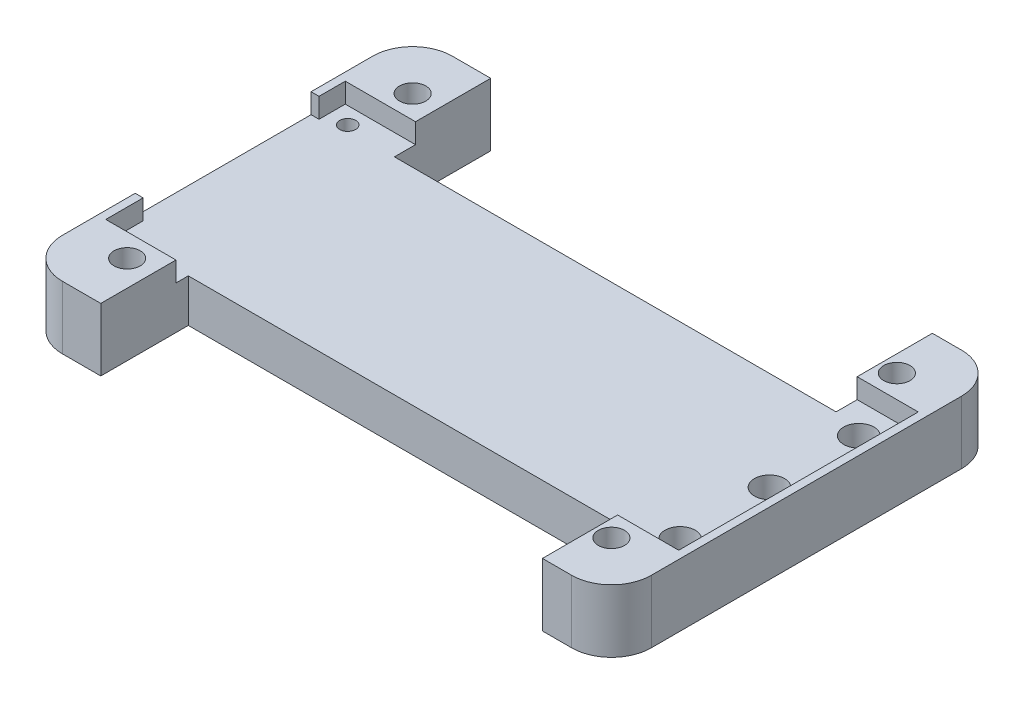
from build123d import *

# Parameters (mm, degrees)
SKETCH1_W           = 74
SKETCH1_H           = 49
BOSS_EXTRUDE1_DEPTH = 7.9
FILLET1_R           = 5
SKETCH3_R           = 1.65
CUT_EXTRUDE6_DEPTH  = 7.9
SKETCH9_R           = 1.9
SKETCH9_R_2         = 1
CUT_EXTRUDE7_DEPTH  = 7.9
CUT_EXTRUDE8_DEPTH  = 2.5
SKETCH11_W          = 55.5
SKETCH11_H          = 12.1
CUT_EXTRUDE9_DEPTH  = 7.9
CUT_EXTRUDE10_DEPTH = 7.9
SKETCH15_W          = 55.5
SKETCH15_H          = 3
CUT_EXTRUDE11_DEPTH = 10


with BuildPart() as part:
    # Sketch1 → Boss-Extrude1 (new body)
    with BuildSketch(Plane(origin=(0, 0, 0), x_dir=(1, 0, 0), z_dir=(0, 1, 0))):
        Rectangle(SKETCH1_W, SKETCH1_H)
    extrude(amount=BOSS_EXTRUDE1_DEPTH)

    # Fillet1
    fillet1_edges = [part.edges().sort_by_distance(p)[0] for p in [
        (37, 3.95, 24.5),
        (-37, 3.95, 24.5),
        (-37, 3.95, -24.5),
        (37, 3.95, -24.5),
    ]]
    fillet(fillet1_edges, radius=FILLET1_R)

    # Sketch3 → Cut-Extrude6 (cut)
    with BuildSketch(Plane(origin=(0, 7.9, 0), x_dir=(1, 0, 0), z_dir=(0, 1, 0))):
        with Locations((-30.424, 17.9375)):
            Circle(SKETCH3_R)
        with Locations((30.424, 17.9375)):
            Circle(SKETCH3_R)
        with Locations((-30.424, -17.9375)):
            Circle(SKETCH3_R)
        with Locations((30.424, -17.9375)):
            Circle(SKETCH3_R)
    extrude(amount=-CUT_EXTRUDE6_DEPTH, mode=Mode.SUBTRACT)

    # Sketch9 → Cut-Extrude7 (cut)
    with BuildSketch(Plane(origin=(0, 7.9, 0), x_dir=(1, 0, 0), z_dir=(0, 1, 0))):
        with Locations((32.354, 11.2275)):
            Circle(SKETCH9_R)
        with Locations((32.354, 0.0025)):
            Circle(SKETCH9_R)
        with Locations((32.354, -11.2275)):
            Circle(SKETCH9_R)
        with Locations((-33.584, 12.9375)):
            Circle(SKETCH9_R_2)
    extrude(amount=-CUT_EXTRUDE7_DEPTH, mode=Mode.SUBTRACT)

    # Sketch10 → Cut-Extrude8 (cut)
    with BuildSketch(Plane(origin=(0, 7.9, 0), x_dir=(1, 0, 0), z_dir=(0, 1, 0))):
        Polygon((36, 15.05), (36, -15.05), (-36, -15.05), (-36, -10.35), (-37, -10.35), (-37, 11.75), (-36, 11.75), (-36, 15.05), align=None)
    extrude(amount=-CUT_EXTRUDE8_DEPTH, mode=Mode.SUBTRACT)

    # Sketch11 → Cut-Extrude9 (cut)
    with BuildSketch(Plane(origin=(0, 7.9, 0), x_dir=(1, 0, 0), z_dir=(0, 1, 0))):
        with Locations((0.574, 18.45)):
            Rectangle(SKETCH11_W, SKETCH11_H)
    extrude(amount=-CUT_EXTRUDE9_DEPTH, mode=Mode.SUBTRACT)

    # Sketch12 → Cut-Extrude10 (cut)
    with BuildSketch(Plane(origin=(0, 7.9, 0), x_dir=(1, 0, 0), z_dir=(0, 1, 0))):
        Polygon((-27.176, -15.05), (-27.176, -13.5), (28.324, -13.5), (28.324, -15.05), (28.324, -21.5), (-27.176, -21.5), align=None)
    extrude(amount=-CUT_EXTRUDE10_DEPTH, mode=Mode.SUBTRACT)

    # Sketch15 → Cut-Extrude11 (cut)
    with BuildSketch(Plane(origin=(0, 7.9, 0), x_dir=(1, 0, 0), z_dir=(0, 1, 0))):
        with Locations((0.574, -23)):
            Rectangle(SKETCH15_W, SKETCH15_H)
    extrude(amount=-CUT_EXTRUDE11_DEPTH, mode=Mode.SUBTRACT)


solid = part.part
